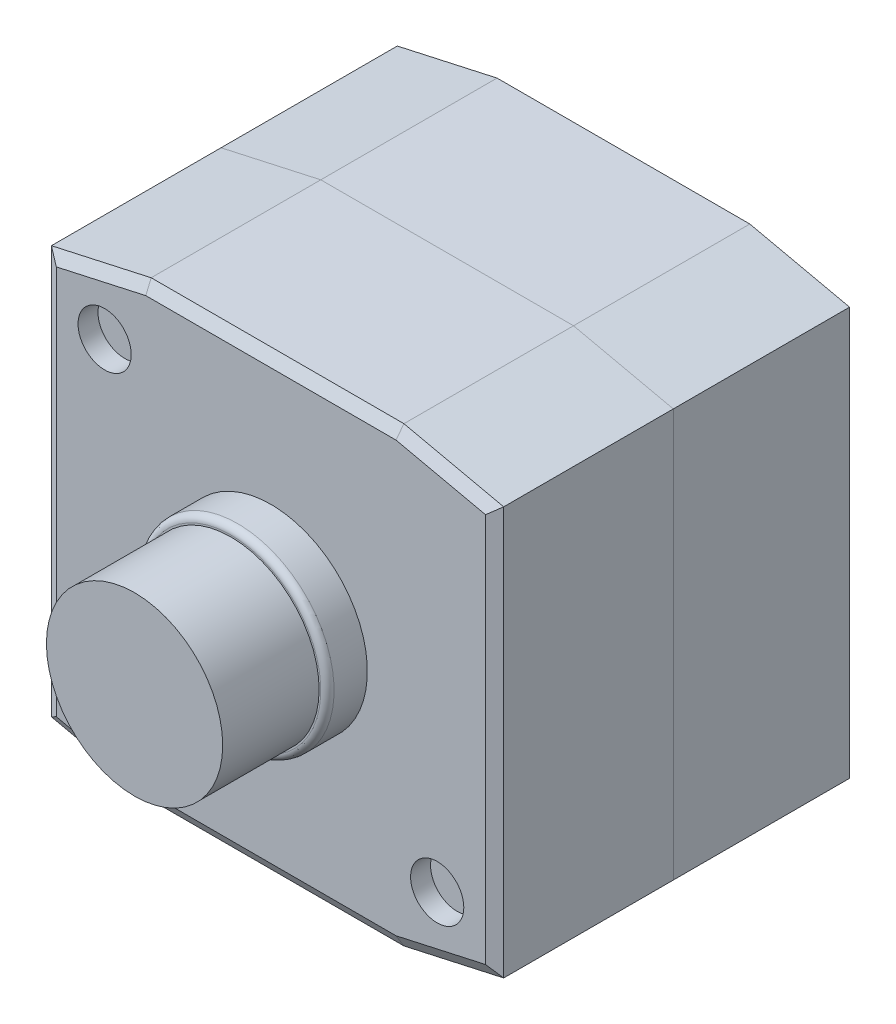
from build123d import *

# Parameters (mm, degrees)
SKETCH4_R                    = 14.5
BOSS_EXTRUDE3_DEPTH          = 6
BOSS_EXTRUDE4_DEPTH          = 26.5
F_8_0_8_DIAMETER_HOLE1_D     = 8
F_8_0_8_DIAMETER_HOLE1_DEPTH = 3
CHAMFER1_SIZE                = 1.732050808
CHAMFER1_SIZE2               = 1
CHAMFER2_SIZE                = 1
CHAMFER2_SIZE2               = 1.732050808
FILLET3_R                    = 1
BOSS_EXTRUDE7_DEPTH          = 26.5
SKETCH41_R                   = 13.25
BOSS_EXTRUDE8_DEPTH          = 14.5


with BuildPart() as part:
    # Sketch4 → Boss-Extrude3 (new body)
    with BuildSketch(Plane.XY.offset(59)):
        with Locations((0, 34)):
            Circle(SKETCH4_R)
    extrude(amount=-BOSS_EXTRUDE3_DEPTH)

    # Sketch5 → Boss-Extrude4 (add)
    with BuildSketch(Plane.XY.offset(53)):
        Polygon((-19, 0), (19, 0), (34, 3.32541994), (34, 64.67458006), (19, 68), (-19, 68), (-34, 64.67458006), (-34, 3.32541994), align=None)
    extrude(amount=-BOSS_EXTRUDE4_DEPTH)

    # Ø8.0 (8) Diameter Hole1
    with Locations(Plane.XY.offset(53)):
        with Locations((-25, 57.5), (25, 10.5)):
            Hole(F_8_0_8_DIAMETER_HOLE1_D / 2, depth=F_8_0_8_DIAMETER_HOLE1_DEPTH)

    # Chamfer1
    chamfer1_edges = [part.edges().sort_by_distance(p)[0] for p in [
        (26.5, 66.33729003, 53),
        (0, 68, 53),
        (-26.5, 66.33729003, 53),
        (-34, 34, 53),
        (-26.5, 1.66270997, 53),
        (0, 0, 53),
        (26.5, 1.66270997, 53),
    ]]
    chamfer1_side = [part.faces().sort_by_distance(p)[0] for p in [
        (0, 0.961665222, 53),
    ]]
    chamfer(chamfer1_edges, length=CHAMFER1_SIZE, length2=CHAMFER1_SIZE2, reference=chamfer1_side[0])

    # Chamfer2
    chamfer2_edges = [part.edges().sort_by_distance(p)[0] for p in [
        (34, 34, 53),
    ]]
    chamfer2_side = [part.faces().sort_by_distance(p)[0] for p in [
        (34, 34, 39.735889277),
    ]]
    chamfer(chamfer2_edges, length=CHAMFER2_SIZE, length2=CHAMFER2_SIZE2, reference=chamfer2_side[0])

    # Fillet3
    fillet3_edges = [part.edges().sort_by_distance(p)[0] for p in [
        (-14.5, 34, 59),
    ]]
    fillet(fillet3_edges, radius=FILLET3_R)

    # Sketch41 → Boss-Extrude8 (add)
    with BuildSketch(Plane.XY.offset(59)):
        with Locations((0, 34)):
            Circle(SKETCH41_R)
    extrude(amount=BOSS_EXTRUDE8_DEPTH)


with BuildPart() as body_2:
    # Sketch40 → Boss-Extrude7 (new body)
    with BuildSketch(Plane(origin=(0, 0, 26.5), x_dir=(-1, 0, 0), z_dir=(0, 0, -1))):
        Polygon((34, 3.32541994), (34, 64.67458006), (19, 68), (-19, 68), (-34, 64.67458006), (-34, 3.32541994), (-19, 0), (19, 0), align=None)
    extrude(amount=BOSS_EXTRUDE7_DEPTH)


solid = Compound([part.part, body_2.part])
